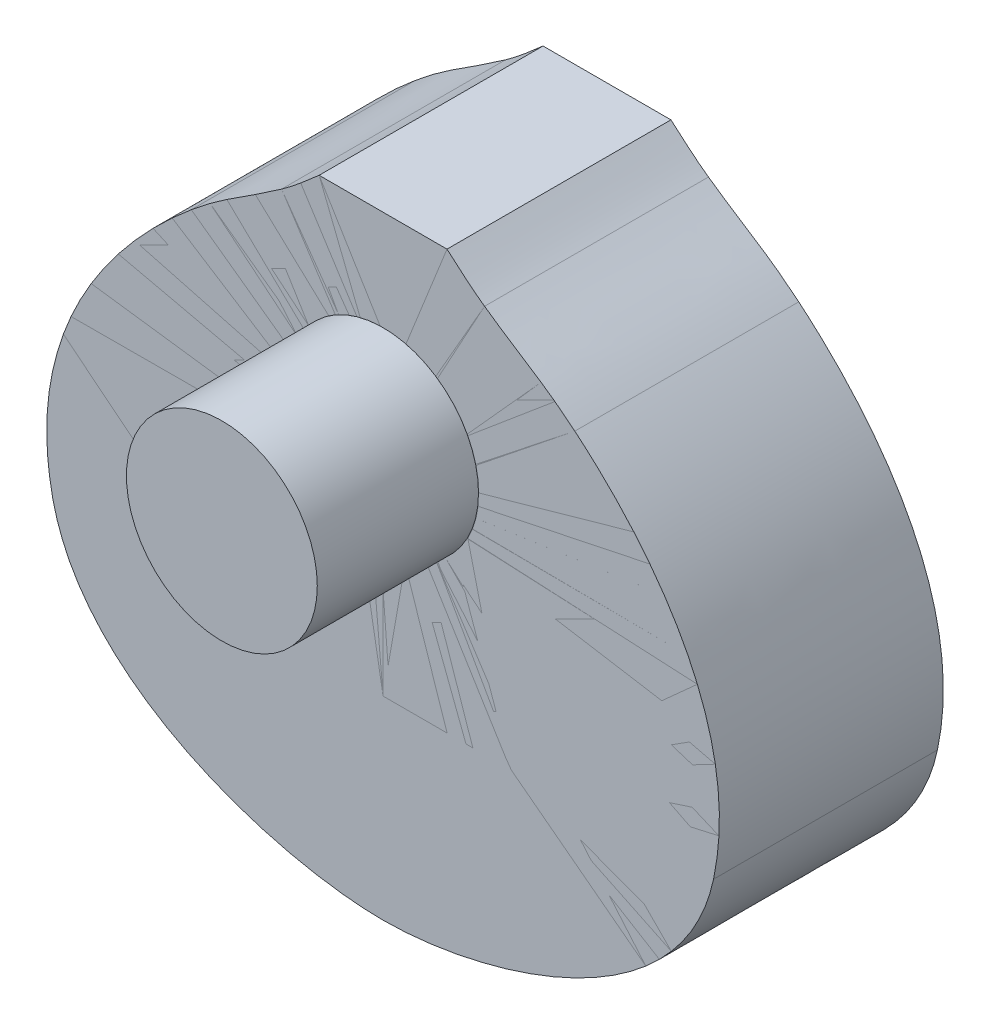
from build123d import *

# Parameters (mm, degrees)
SALIENTE_EXTRUIR1_DEPTH = 100
SALIENTE_EXTRUIR2_DEPTH = 100
CROQUIS13_R             = 42.623507313
SALIENTE_EXTRUIR3_DEPTH = 72


with BuildPart() as part:
    # Croquis1 → Saliente-Extruir1 (new body)
    with BuildSketch(Plane.XY):
        with BuildLine():
            Line((-28.560802162, 136.916395712), (2.54e-07, 136.916395712))
            Line((2.54e-07, 136.916395712), (2.54e-07, -136.916395712))
            add(Edge.make_bspline(
                [(2.54e-07, -136.916395712), (-46.441340442, -136.916395602), (-133.83340639, -111.670406771), (-147.578497366, -47.27649641)],
                knots=[0, 0, 0, 0, 1, 1, 1, 1], degree=3))
            add(Edge.make_bspline(
                [(-147.578497366, -47.27649641), (-163.110192587, 25.487257565), (-105.360717743, 78.580885367), (-85.639397682, 95.058759336)],
                knots=[0, 0, 0, 0, 1, 1, 1, 1], degree=3))
            add(Edge.make_bspline(
                [(-85.639397682, 95.058759336), (-70.778695882, 107.475422336), (-62.78576597, 110.83954464), (-45.323206026, 123.188624336)],
                knots=[0, 0, 0, 0, 1, 1, 1, 1], degree=3))
            add(Edge.make_bspline(
                [(-45.323206026, 123.188624336), (-39.50234289, 127.304974752), (-33.933522938, 132.194713512), (-28.560802162, 136.916395712)],
                knots=[0, 0, 0, 0, 1, 1, 1, 1], degree=3))
        make_face()
    extrude(amount=SALIENTE_EXTRUIR1_DEPTH)

    # Croquis3 → Saliente-Extruir2 (add)
    with BuildSketch(Plane.XY):
        with BuildLine():
            Line((2.54e-07, 136.916395712), (0, -136.916395712))
            add(Edge.make_bspline(
                [(0, -136.916395712), (46.441340696, -136.916395629), (133.833406659, -111.67040685), (147.578497673, -47.276496498)],
                knots=[0, 0, 0, 0, 1, 1, 1, 1], degree=3))
            add(Edge.make_bspline(
                [(147.578497673, -47.276496498), (163.110192997, 25.487257456), (105.360718228, 78.58088534), (85.63939819, 95.058759336)],
                knots=[0, 0, 0, 0, 1, 1, 1, 1], degree=3))
            add(Edge.make_bspline(
                [(85.63939819, 95.058759336), (70.77869639, 107.475422336), (62.785766478, 110.83954464), (45.323206534, 123.188624336)],
                knots=[0, 0, 0, 0, 1, 1, 1, 1], degree=3))
            add(Edge.make_bspline(
                [(45.323206534, 123.188624336), (39.502343398, 127.304974752), (33.933523446, 132.194713512), (28.56080267, 136.916395712)],
                knots=[0, 0, 0, 0, 1, 1, 1, 1], degree=3))
            Line((28.56080267, 136.916395712), (2.54e-07, 136.916395712))
        make_face()
    extrude(amount=SALIENTE_EXTRUIR2_DEPTH)

    # Croquis13 → Saliente-Extruir3 (add)
    with BuildSketch(Plane.XY.offset(100)):
        with Locations((2.54e-07, 49.659481629)):
            Circle(CROQUIS13_R)
    extrude(amount=SALIENTE_EXTRUIR3_DEPTH)


solid = part.part
